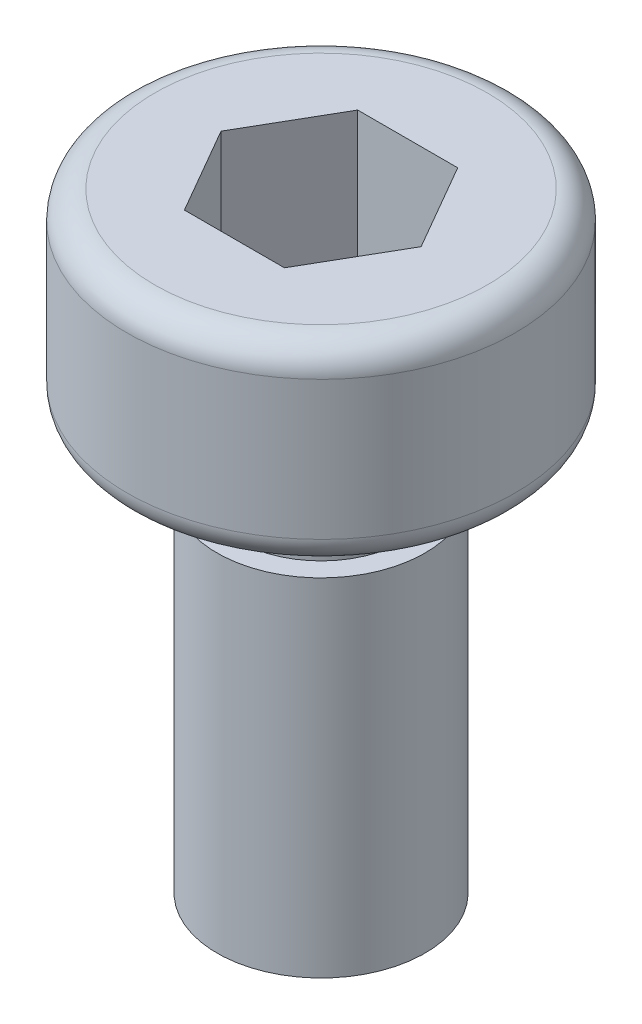
from build123d import *

# Parameters (mm, degrees)
CUT_EXTRUDE_1_DEPTH = 2


with BuildPart() as part:
    # 草图1 → 旋转1 (revolve)
    with BuildSketch(Plane.XY):
        with BuildLine():
            Line((0, 8.8), (-2.4, 8.8))
            ThreePointArc((-2.4, 8.8), (-2.682842712, 8.682842712), (-2.8, 8.4))
            Line((-2.8, 8.4), (-2.8, 6.4))
            ThreePointArc((-2.8, 6.4), (-2.682842712, 6.117157288), (-2.4, 6))
            Line((-2.4, 6), (-1.2, 6))
            Line((-1.2, 6), (-1.2, 5))
            Line((-1.2, 5), (-1.5, 5))
            Line((-1.5, 5), (-1.5, 0))
            Line((-1.5, 0), (0, 0))
            Line((0, 0), (0, 8.8))
        make_face()
    revolve(axis=Axis((0, 0, 0), (0, 1, 0)))

    # 草图2 → 切除-拉伸1 (cut)
    with BuildSketch(Plane(origin=(0, 8.8, 0), x_dir=(1, 0, 0), z_dir=(0, 1, 0))):
        Polygon((-0.721687836, 1.25), (-1.443375673, 0), (-0.721687836, -1.25), (0.721687836, -1.25), (1.443375673, 0), (0.721687836, 1.25), align=None)
    extrude(amount=-CUT_EXTRUDE_1_DEPTH, mode=Mode.SUBTRACT)


solid = part.part
